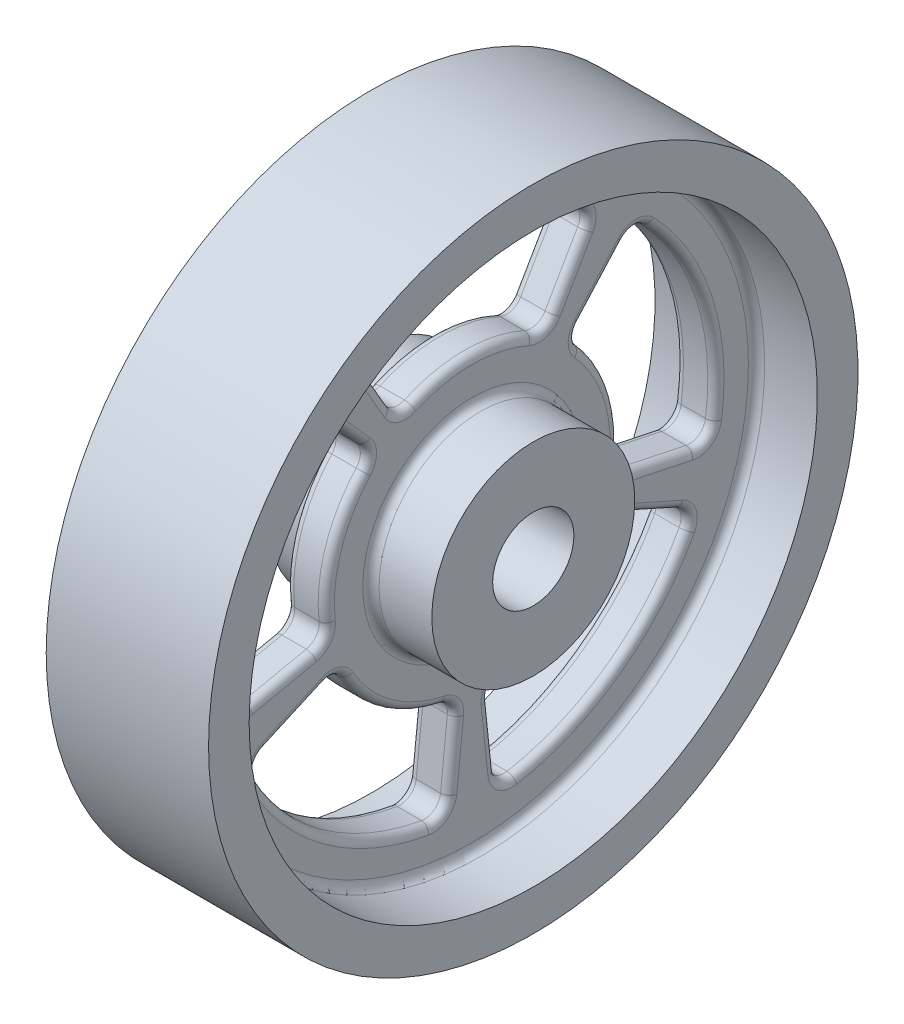
from build123d import *

# Parameters (mm, degrees)
CUT_EXTRUDE1_DEPTH       = 13.5
FILLET2_R                = 2
CIRPATTERN1_COUNT        = 5
FILLET2_OF_CIRPATTERN1_R = 2
FILLET3_R                = 1
FILLET4_R                = 1


with BuildPart() as part:
    # Sketch1 → Revolve1 (revolve)
    with BuildSketch(Plane.XY):
        Polygon((2.5, 35), (10, 35), (10, 40), (-10, 40), (-10, 35), (-2.5, 35), (-2.5, 12.5), (-10, 12.5), (-10, 5), (10, 5), (10, 12.5), (2.5, 12.5), align=None)
    revolve(axis=Axis((0, 0, 0), (1, 0, 0)))

    # Sketch2 → Cut-Extrude1 (cut, through all)
    with BuildSketch(Plane(origin=(2.5, 0, 0), x_dir=(0, 0, -1), z_dir=(1, 0, 0))):
        with BuildLine():
            Line((-15, 25.980762114), (-9, 15.588457268))
            ThreePointArc((-9, 15.588457268), (0, 18), (9, 15.588457268))
            Line((9, 15.588457268), (15, 25.980762114))
            ThreePointArc((15, 25.980762114), (0, 30), (-15, 25.980762114))
        make_face()
    cut_extrude1 = extrude(amount=-CUT_EXTRUDE1_DEPTH, mode=Mode.SUBTRACT)

    # Fillet2
    fillet2_edges = [part.edges().sort_by_distance(p)[0] for p in [
        (0, 25.980762114, 15),
        (0, 25.980762114, -15),
        (0, 15.588457268, -9),
        (0, 15.588457268, 9),
    ]]
    fillet(fillet2_edges, radius=FILLET2_R)

    # CirPattern1: Cut-Extrude1 ×5 about axis
    cirpattern1_axis = Axis((0, 0, 0), (1, 0, 0))
    for i in range(1, CIRPATTERN1_COUNT):
        add(cut_extrude1.rotate(cirpattern1_axis, i * 360 / CIRPATTERN1_COUNT), mode=Mode.SUBTRACT)

    # Fillet2 of CirPattern1
    fillet2_of_cirpattern1_edges = [part.edges().sort_by_distance(p)[0] for p in [
        (0, -6.237350725, 29.344428022),
        (0, 22.294344764, 20.073918191),
        (0, 13.376606859, 12.044350914),
        (0, -3.742410435, 17.606656813),
        (0, -29.835656861, 3.135853898),
        (0, -12.202099292, 27.406363729),
        (0, -7.321259575, 16.443818238),
        (0, -17.901394117, 1.881512339),
        (0, -12.202099292, -27.406363729),
        (0, -29.835656861, -3.135853898),
        (0, -17.901394117, -1.881512339),
        (0, -7.321259575, -16.443818238),
        (0, 22.294344764, -20.073918191),
        (0, -6.237350725, -29.344428022),
        (0, -3.742410435, -17.606656813),
        (0, 13.376606859, -12.044350914),
    ]]
    fillet(fillet2_of_cirpattern1_edges, radius=FILLET2_OF_CIRPATTERN1_R)

    # Fillet3
    fillet3_edges = [part.edges().sort_by_distance(p)[0] for p in [
        (2.5, -12.5, 0),
        (2.5, -35, 0),
        (2.5, 17.771650383, -16.001665879),
        (2.5, 9.270509831, -28.531695489),
        (2.5, 5.562305899, -17.119017293),
        (2.5, -4.972023962, -23.391533639),
        (2.5, 21.416368191, -20.14086169),
        (2.5, 13.445581763, -12.801825774),
        (2.5, -5.487704354, -28.882524769),
        (2.5, -3.352979753, -18.260009279),
        (2.5, -9.726746619, -21.846630597),
        (2.5, -24.270509831, -17.633557569),
        (2.5, -14.562305899, -10.580134541),
        (2.5, -23.783110394, -2.49970563),
        (2.5, -12.537076026, -26.592045067),
        (2.5, -8.020346559, -16.743489875),
        (2.5, -29.164707294, -3.706074009),
        (2.5, -18.402428538, -2.453779941),
        (2.5, -23.783110394, 2.49970563),
        (2.5, -24.270509831, 17.633557569),
        (2.5, -14.562305899, 10.580134541),
        (2.5, -9.726746619, 21.846630597),
        (2.5, -29.164707294, 3.706074009),
        (2.5, -18.402428538, 2.453779941),
        (2.5, -12.537076026, 26.592045067),
        (2.5, -8.020346559, 16.743489875),
        (2.5, -4.972023962, 23.391533639),
        (2.5, 9.270509831, 28.531695489),
        (2.5, 5.562305899, 17.119017293),
        (2.5, 17.771650383, 16.001665879),
        (2.5, -5.487704354, 28.882524769),
        (2.5, -3.352979753, 18.260009279),
        (2.5, 21.416368191, 20.14086169),
        (2.5, 13.445581763, 12.801825774),
        (2.5, 20.710230592, 11.957057207),
        (2.5, 30, 0),
        (2.5, 18, 0),
        (2.5, 20.710230592, -11.957057207),
        (2.5, 25.773119483, 14.14430798),
        (2.5, 16.330173087, 8.831526428),
        (2.5, 25.773119483, -14.14430798),
        (2.5, 16.330173087, -8.831526428),
    ]]
    fillet(fillet3_edges, radius=FILLET3_R)

    # Fillet4
    fillet4_edges = [part.edges().sort_by_distance(p)[0] for p in [
        (-2.5, -35, 0),
        (-2.5, -12.5, 0),
        (-2.5, 17.771650383, -16.001665879),
        (-2.5, 9.270509831, -28.531695489),
        (-2.5, 5.562305899, -17.119017293),
        (-2.5, -4.972023962, -23.391533639),
        (-2.5, 21.416368191, -20.14086169),
        (-2.5, 13.445581763, -12.801825774),
        (-2.5, -5.487704354, -28.882524769),
        (-2.5, -3.352979753, -18.260009279),
        (-2.5, -9.726746619, -21.846630597),
        (-2.5, -24.270509831, -17.633557569),
        (-2.5, -14.562305899, -10.580134541),
        (-2.5, -23.783110394, -2.49970563),
        (-2.5, -12.537076026, -26.592045067),
        (-2.5, -8.020346559, -16.743489875),
        (-2.5, -29.164707294, -3.706074009),
        (-2.5, -18.402428538, -2.453779941),
        (-2.5, -23.783110394, 2.49970563),
        (-2.5, -24.270509831, 17.633557569),
        (-2.5, -14.562305899, 10.580134541),
        (-2.5, -9.726746619, 21.846630597),
        (-2.5, -29.164707294, 3.706074009),
        (-2.5, -18.402428538, 2.453779941),
        (-2.5, -12.537076026, 26.592045067),
        (-2.5, -8.020346559, 16.743489875),
        (-2.5, -4.972023962, 23.391533639),
        (-2.5, 9.270509831, 28.531695489),
        (-2.5, 5.562305899, 17.119017293),
        (-2.5, 17.771650383, 16.001665879),
        (-2.5, -5.487704354, 28.882524769),
        (-2.5, -3.352979753, 18.260009279),
        (-2.5, 21.416368191, 20.14086169),
        (-2.5, 13.445581763, 12.801825774),
        (-2.5, 20.710230592, 11.957057207),
        (-2.5, 30, 0),
        (-2.5, 18, 0),
        (-2.5, 20.710230592, -11.957057207),
        (-2.5, 25.773119483, 14.14430798),
        (-2.5, 16.330173087, 8.831526428),
        (-2.5, 25.773119483, -14.14430798),
        (-2.5, 16.330173087, -8.831526428),
    ]]
    fillet(fillet4_edges, radius=FILLET4_R)


solid = part.part
